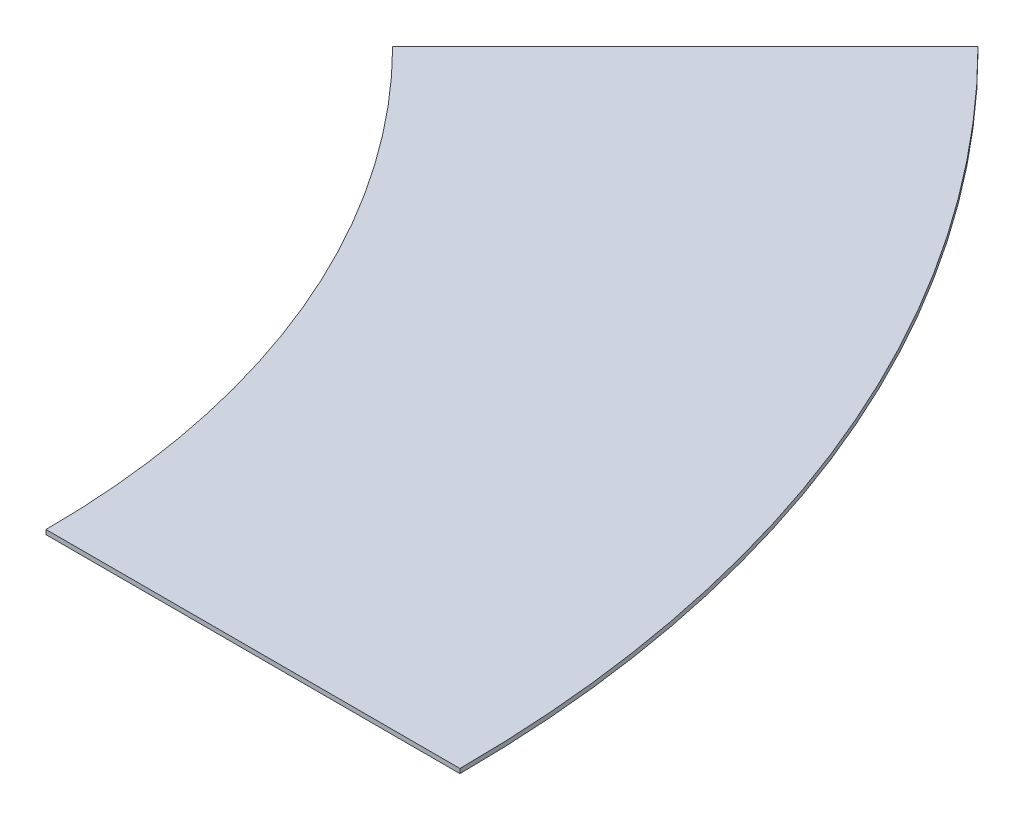
from build123d import *

# Parameters (mm, degrees)
SKETCH2_W      = 460
SKETCH2_H      = 5
REVOLVE1_ANGLE = 45


with BuildPart() as part:
    # Sketch2 → Revolve1 (revolve)
    with BuildSketch(Plane.XY):
        with Locations((1160, 0)):
            Rectangle(SKETCH2_W, SKETCH2_H)
    revolve(axis=Axis((0, 0, 0), (0, 1, 0)), revolution_arc=REVOLVE1_ANGLE)


solid = part.part
